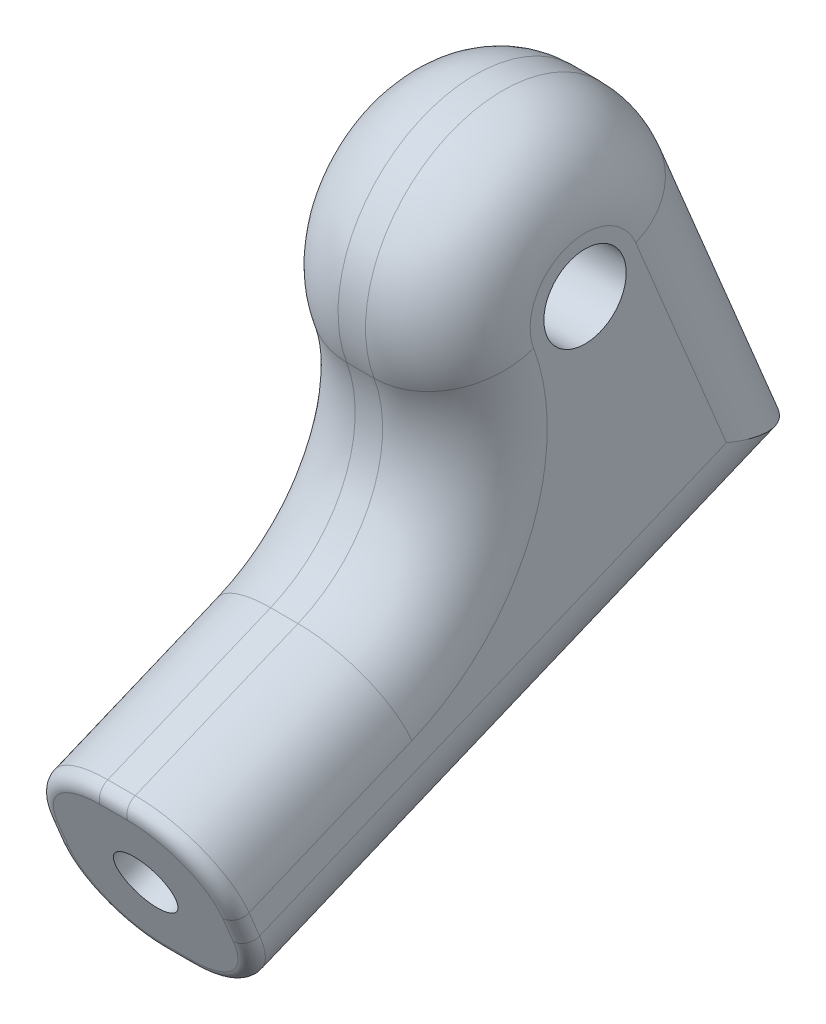
from build123d import *

# Parameters (mm, degrees)
SKETCH1_R           = 1.5
BOSS_EXTRUDE1_DEPTH = 7
FILLET1_R           = 5
FILLET2_R           = 3
SKETCH2_R           = 1.1
CUT_EXTRUDE1_DEPTH  = 28.212210096
CUT_EXTRUDE2_DEPTH  = 2.2
FILLET3_R           = 0.5


with BuildPart() as part:
    # Sketch1 → Boss-Extrude1 (new body)
    with BuildSketch(Plane(origin=(0, 0, 0), x_dir=(0, 0, -1), z_dir=(1, 0, 0))):
        with BuildLine():
            Line((0, -5), (-13.854054376, -10.750232807))
            Line((-13.854054376, -10.750232807), (-11.1706124, -17.215458183))
            Line((-11.1706124, -17.215458183), (9.071772057, -8.813699388))
            Line((9.071772057, -8.813699388), (4.618018125, 1.916744269))
            ThreePointArc((4.618018125, 1.916744269), (-4.158348311, 2.776353603), (0, -5))
        make_face()
        Circle(SKETCH1_R, mode=Mode.SUBTRACT)
    extrude(amount=BOSS_EXTRUDE1_DEPTH)

    # Fillet1
    fillet1_edges = [part.edges().sort_by_distance(p)[0] for p in [
        (3.5, -5, 0),
    ]]
    fillet(fillet1_edges, radius=FILLET1_R)

    # Fillet2
    fillet2_edges = [part.edges().sort_by_distance(p)[0] for p in [
        (7, -13.014578785, 1.049420171),
        (0, -9.423070941, 10.656519028),
        (7, -9.423070941, 10.656519028),
        (7, -3.44847756, -6.844895091),
        (0, -5.475900192, 4.79228393),
        (7, -5.475900192, 4.79228393),
        (7, 4.653790231, 1.828178461),
        (0, -3.44847756, -6.844895091),
        (0, -13.014578785, 1.049420171),
        (0, 4.653790231, 1.828178461),
    ]]
    fillet(fillet2_edges, radius=FILLET2_R)

    # Sketch2 → Cut-Extrude1 (cut, through all)
    with BuildSketch(Plane(origin=(0, -6.485014526, 15.624366332), x_dir=(1, 0, 0), z_dir=(0, -0.383348854, 0.923603625))):
        with Locations((3.5, -8.118018125)):
            Circle(SKETCH2_R)
    extrude(amount=-CUT_EXTRUDE1_DEPTH, mode=Mode.SUBTRACT)

    # Sketch3 → Cut-Extrude2 (cut)
    with BuildSketch(Plane.ZY):
        Polygon((2.385343934, 1.827610275), (-0.39008496, 2.979573581), (-2.775428893, 1.151963306), (-2.385343934, -1.827610275), (0.39008496, -2.979573581), (2.775428893, -1.151963306), align=None)
    extrude(amount=-CUT_EXTRUDE2_DEPTH, mode=Mode.SUBTRACT)

    # Fillet3
    fillet3_edges = [part.edges().sort_by_distance(p)[0] for p in [
        (0, -13.982845495, 12.512333388),
        (7, -13.982845495, 12.512333388),
        (3.5, -10.750232807, 13.854054376),
        (3.5, -17.215458183, 11.1706124),
        (6.121320344, -16.403906467, 11.507453239),
        (6.121320344, -11.561784523, 13.517213537),
        (0.878679656, -16.403906467, 11.507453239),
        (0.878679656, -11.561784523, 13.517213537),
    ]]
    fillet(fillet3_edges, radius=FILLET3_R)


solid = part.part
